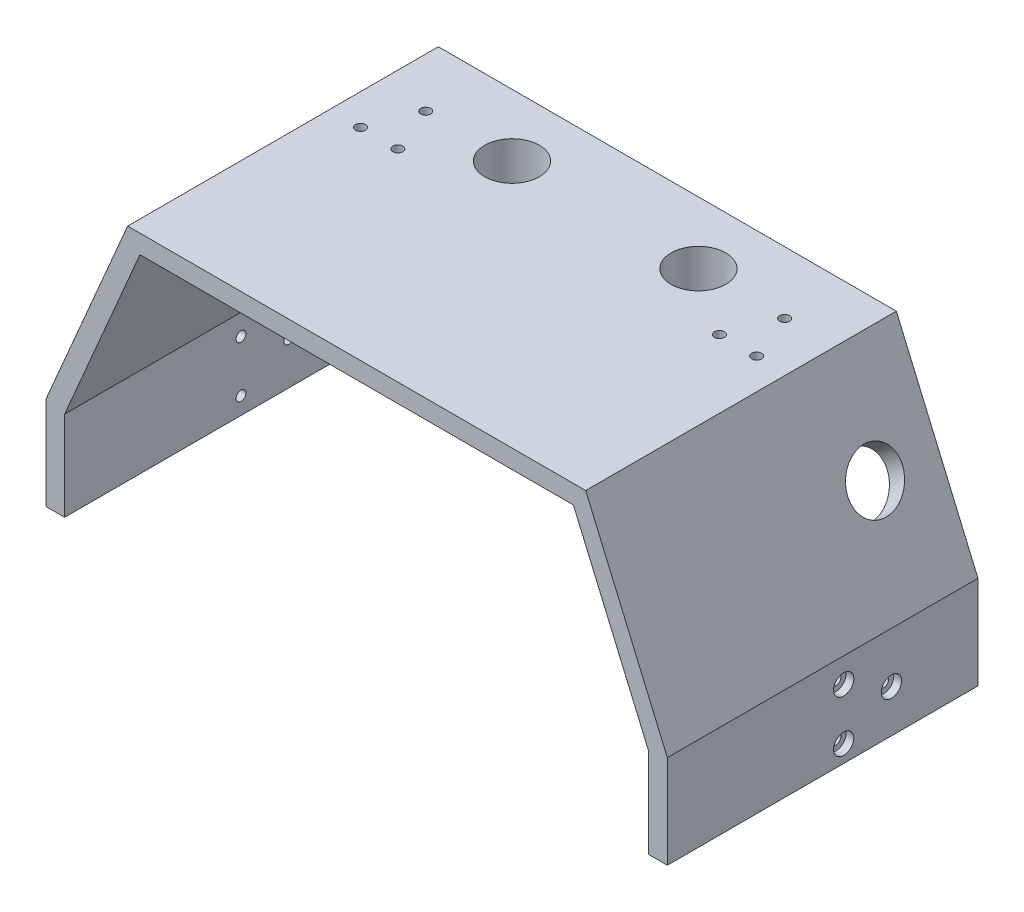
from build123d import *

# Parameters (mm, degrees)
SALIENTE_EXTRUIR1_DEPTH = 100
CORTAR_EXTRUIR1_REACH   = 170.346
CROQUIS3_R              = 8.8
CORTAR_EXTRUIR2_REACH   = 226.945
CROQUIS4_R              = 8.8
CORTAR_EXTRUIR3_DEPTH   = 0.5
CORTAR_EXTRUIR4_REACH   = 241.691
CROQUIS6_R              = 1.6
CROQUIS7_R              = 3.25
CORTAR_EXTRUIR5_DEPTH   = 2.5
CROQUIS11_R             = 10.3
CROQUIS11_R_2           = 8.8
SALIENTE_EXTRUIR2_DEPTH = 10
SALIENTE_EXTRUIR3_REACH = 201.802
CROQUIS12_R             = 10.3
CROQUIS12_R_2           = 8.8
CORTAR_EXTRUIR9_REACH   = 167.168
CROQUIS13_R             = 1.6


with BuildPart() as part:
    # Croquis1 → Saliente-Extruir1 (new body)
    with BuildSketch(Plane.XY):
        Polygon((-100, 25), (-100, -5), (-94, -5), (-94, 23.768453788), (-69.761533754, 80.324875029), (69.761533754, 80.324875029), (94, 23.768453788), (94, -5), (100, -5), (100, 25), (73.717910702, 86.324875029), (-73.717910702, 86.324875029), align=None)
    extrude(amount=SALIENTE_EXTRUIR1_DEPTH)

    # Croquis3 → Cortar-Extruir1 (cut, up to next)
    with BuildSketch(Plane(origin=(0, 86.324875029, 0), x_dir=(1, 0, 0), z_dir=(0, 1, 0)), mode=Mode.PRIVATE) as cortar_extruir1_sk1:
        with Locations(Location((-30, -20, 0), (0, 0, 270))):
            Circle(CROQUIS3_R)
    cortar_extruir1_tool1 = extrude(cortar_extruir1_sk1.sketch, amount=-CORTAR_EXTRUIR1_REACH, mode=Mode.PRIVATE) & part.part
    # Croquis3 → Cortar-Extruir1 (cut, up to next)
    with BuildSketch(Plane(origin=(0, 86.324875029, 0), x_dir=(1, 0, 0), z_dir=(0, 1, 0)), mode=Mode.PRIVATE) as cortar_extruir1_sk2:
        with Locations(Location((30, -20, 0), (0, 0, 270))):
            Circle(CROQUIS3_R)
    cortar_extruir1_tool2 = extrude(cortar_extruir1_sk2.sketch, amount=-CORTAR_EXTRUIR1_REACH, mode=Mode.PRIVATE) & part.part
    add(cortar_extruir1_tool1.solids().sort_by_distance((-30, 86.324875, 20))[0], mode=Mode.SUBTRACT)
    add(cortar_extruir1_tool2.solids().sort_by_distance((30, 86.324875, 20))[0], mode=Mode.SUBTRACT)

    # Cortar-Extruir2: up to this plane
    cortar_extruir2_end = Plane(origin=(-94, 23.768453788, 100), z_dir=(-0.9191450300180581, 0.3939192985791672, 0))
    # Croquis4 → Cortar-Extruir2 (cut, up to the surface)
    with BuildSketch(Plane(origin=(-87.479517168, 68.836107355, 0), x_dir=(0, 0, -1), z_dir=(-0.7858721058939679, 0.6183890629512945, 0)), mode=Mode.PRIVATE) as cortar_extruir2_sk1:
        with Locations(Location((-20, 9.96907102, 0), (0, 0, 270))):
            Circle(CROQUIS4_R)
    cortar_extruir2_tool1 = split(extrude(cortar_extruir2_sk1.sketch, amount=-CORTAR_EXTRUIR2_REACH, mode=Mode.PRIVATE), bisect_by=cortar_extruir2_end, keep=Keep.BOTH, mode=Mode.PRIVATE)
    cortar_extruir2 = cortar_extruir2_tool1.solids().sort_by_distance((-93.644282, 61.001693, 20))[0]
    add(cortar_extruir2, mode=Mode.SUBTRACT)

    # Simetría1: Cortar-Extruir2 across plane
    add(cortar_extruir2.mirror(Plane(origin=(0, 0, 0), x_dir=(0, 0, 1), z_dir=(1, 0, 0))), mode=Mode.SUBTRACT)

    # Croquis5 → Cortar-Extruir3 (cut)
    with BuildSketch(Plane.XZ.offset(-80.324875029)):
        with BuildLine():
            Line((14.875, 0), (15.175, 0))
            Line((15.175, 0), (15.175, 2.3))
            Line((15.175, 2.3), (3.784177586, 2.3))
            ThreePointArc((3.784177586, 2.3), (0, 3.1), (-3.784177586, 2.3))
            Line((-3.784177586, 2.3), (-15.175, 2.3))
            Line((-15.175, 2.3), (-15.175, 0))
            Line((-15.175, 0), (-14.875, 0))
            Line((-14.875, 0), (-14.875, 2))
            Line((-14.875, 2), (-3.720215048, 2))
            ThreePointArc((-3.720215048, 2), (0, 2.8), (3.720215048, 2))
            Line((3.720215048, 2), (14.875, 2))
            Line((14.875, 2), (14.875, 0))
        make_face()
        with BuildLine():
            Line((3.261901286, 0), (14.875, 0))
            Line((14.875, 0), (14.875, 2))
            Line((14.875, 2), (3.720215048, 2))
            ThreePointArc((3.720215048, 2), (0, 2.8), (-3.720215048, 2))
            Line((-3.720215048, 2), (-14.875, 2))
            Line((-14.875, 2), (-14.875, 0))
            Line((-14.875, 0), (-3.261901286, 0))
            ThreePointArc((-3.261901286, 0), (0, 0.8), (3.261901286, 0))
        make_face()
        with BuildLine():
            Line((-3.261901286, 0), (3.261901286, 0))
            ThreePointArc((3.261901286, 0), (0, 0.8), (-3.261901286, 0))
        make_face()
    extrude(amount=-CORTAR_EXTRUIR3_DEPTH, mode=Mode.SUBTRACT)

    # Croquis6 → Cortar-Extruir4 (cut, up to next)
    with BuildSketch(Plane.ZY.offset(100), mode=Mode.PRIVATE) as cortar_extruir4_sk1:
        with Locations(Location((43.227046774, 0.497681725, 0), (0, 0, 270))):
            Circle(CROQUIS6_R)
    cortar_extruir4_tool1 = extrude(cortar_extruir4_sk1.sketch, amount=-CORTAR_EXTRUIR4_REACH, mode=Mode.PRIVATE) & part.part
    # Croquis6 → Cortar-Extruir4 (cut, up to next)
    with BuildSketch(Plane.ZY.offset(100), mode=Mode.PRIVATE) as cortar_extruir4_sk2:
        with Locations(Location((27.863523387, 8.768453788, 0), (0, 0, 270))):
            Circle(CROQUIS6_R)
    cortar_extruir4_tool2 = extrude(cortar_extruir4_sk2.sketch, amount=-CORTAR_EXTRUIR4_REACH, mode=Mode.PRIVATE) & part.part
    # Croquis6 → Cortar-Extruir4 (cut, up to next)
    with BuildSketch(Plane.ZY.offset(100), mode=Mode.PRIVATE) as cortar_extruir4_sk3:
        with Locations(Location((43.227046774, 17.039225851, 0), (0, 0, 270))):
            Circle(CROQUIS6_R)
    cortar_extruir4_tool3 = extrude(cortar_extruir4_sk3.sketch, amount=-CORTAR_EXTRUIR4_REACH, mode=Mode.PRIVATE) & part.part
    cortar_extruir4_1 = cortar_extruir4_tool1.solids().sort_by_distance((-100, 0.497682, 43.227047))[0]
    add(cortar_extruir4_1, mode=Mode.SUBTRACT)
    cortar_extruir4_2 = cortar_extruir4_tool2.solids().sort_by_distance((-100, 8.768454, 27.863523))[0]
    add(cortar_extruir4_2, mode=Mode.SUBTRACT)
    cortar_extruir4_3 = cortar_extruir4_tool3.solids().sort_by_distance((-100, 17.039226, 43.227047))[0]
    add(cortar_extruir4_3, mode=Mode.SUBTRACT)
    cortar_extruir4 = cortar_extruir4_1 + cortar_extruir4_2 + cortar_extruir4_3  # Cortar-Extruir4 as one shape, for the pattern or mirror that repeats it

    # Croquis7 → Cortar-Extruir5 (cut)
    with BuildSketch(Plane.ZY.offset(100)):
        with Locations(Location((27.863523387, 8.768453788, 0), (0, 0, 270))):
            Circle(CROQUIS7_R)
        with Locations(Location((43.227046774, 0.497681725, 0), (0, 0, 270))):
            Circle(CROQUIS7_R)
        with Locations(Location((43.227046774, 17.039225851, 0), (0, 0, 270))):
            Circle(CROQUIS7_R)
    cortar_extruir5 = extrude(amount=-CORTAR_EXTRUIR5_DEPTH, mode=Mode.SUBTRACT)

    # Simetría2: Cortar-Extruir4, Cortar-Extruir5 across plane
    add(cortar_extruir4.mirror(Plane(origin=(0, 0, 0), x_dir=(0, 0, 1), z_dir=(1, 0, 0))), mode=Mode.SUBTRACT)
    add(cortar_extruir5.mirror(Plane(origin=(0, 0, 0), x_dir=(0, 0, 1), z_dir=(1, 0, 0))), mode=Mode.SUBTRACT)

    # Croquis11 → Saliente-Extruir2 (add)
    with BuildSketch(Plane.XZ.offset(-80.324875029)):
        with Locations(Location((-30, 20, 0), (0, 0, 90))):
            Circle(CROQUIS11_R)
        with Locations(Location((-30, 20, 0), (0, 0, 90))):
            Circle(CROQUIS11_R_2, mode=Mode.SUBTRACT)
        with Locations(Location((30, 20, 0), (0, 0, 90))):
            Circle(CROQUIS11_R)
        with Locations(Location((30, 20, 0), (0, 0, 90))):
            Circle(CROQUIS11_R_2, mode=Mode.SUBTRACT)
    extrude(amount=SALIENTE_EXTRUIR2_DEPTH)

    # Saliente-Extruir3: up to this plane
    saliente_extruir3_end = Plane(origin=(-94, 23.768453788, 100), z_dir=(-0.9191450300180581, 0.3939192985791672, 0))
    # Croquis12 → Saliente-Extruir3 (add, up to the surface)
    with BuildSketch(Plane(origin=(-63.903353991, 50.284435467, 0), x_dir=(0, 0, -1), z_dir=(-0.7858721058939679, 0.6183890629512945, 0)), mode=Mode.PRIVATE) as saliente_extruir3_sk1:
        with Locations(Location((-20, 9.96907102, 0), (0, 0, 90))):
            Circle(CROQUIS12_R)
        with Locations(Location((-20, 9.96907102, 0), (0, 0, 90))):
            Circle(CROQUIS12_R_2, mode=Mode.SUBTRACT)
    saliente_extruir3_tool1 = split(extrude(saliente_extruir3_sk1.sketch, amount=SALIENTE_EXTRUIR3_REACH, mode=Mode.PRIVATE), bisect_by=saliente_extruir3_end, keep=Keep.BOTH, mode=Mode.PRIVATE)
    add(saliente_extruir3_tool1.solids().sort_by_distance((-63.878865, 50.315557, 20))[0])

    # Croquis13 → Cortar-Extruir9 (cut, up to next)
    with BuildSketch(Plane.XZ.offset(-80.324875029), mode=Mode.PRIVATE) as cortar_extruir9_sk1:
        with Locations(Location((57.761533754, 20, 0), (0, 0, 270))):
            Circle(CROQUIS13_R)
    cortar_extruir9_tool1 = extrude(cortar_extruir9_sk1.sketch, amount=-CORTAR_EXTRUIR9_REACH, mode=Mode.PRIVATE) & part.part
    # Croquis13 → Cortar-Extruir9 (cut, up to next)
    with BuildSketch(Plane.XZ.offset(-80.324875029), mode=Mode.PRIVATE) as cortar_extruir9_sk2:
        with Locations(Location((51.761533754, 35, 0), (0, 0, 270))):
            Circle(CROQUIS13_R)
    cortar_extruir9_tool2 = extrude(cortar_extruir9_sk2.sketch, amount=-CORTAR_EXTRUIR9_REACH, mode=Mode.PRIVATE) & part.part
    # Croquis13 → Cortar-Extruir9 (cut, up to next)
    with BuildSketch(Plane.XZ.offset(-80.324875029), mode=Mode.PRIVATE) as cortar_extruir9_sk3:
        with Locations(Location((63.761533754, 35, 0), (0, 0, 270))):
            Circle(CROQUIS13_R)
    cortar_extruir9_tool3 = extrude(cortar_extruir9_sk3.sketch, amount=-CORTAR_EXTRUIR9_REACH, mode=Mode.PRIVATE) & part.part
    # Croquis13 → Cortar-Extruir9 (cut, up to next)
    with BuildSketch(Plane.XZ.offset(-80.324875029), mode=Mode.PRIVATE) as cortar_extruir9_sk4:
        with Locations(Location((-57.761533754, 20, 0), (0, 0, 270))):
            Circle(CROQUIS13_R)
    cortar_extruir9_tool4 = extrude(cortar_extruir9_sk4.sketch, amount=-CORTAR_EXTRUIR9_REACH, mode=Mode.PRIVATE) & part.part
    # Croquis13 → Cortar-Extruir9 (cut, up to next)
    with BuildSketch(Plane.XZ.offset(-80.324875029), mode=Mode.PRIVATE) as cortar_extruir9_sk5:
        with Locations(Location((-63.761533754, 35, 0), (0, 0, 270))):
            Circle(CROQUIS13_R)
    cortar_extruir9_tool5 = extrude(cortar_extruir9_sk5.sketch, amount=-CORTAR_EXTRUIR9_REACH, mode=Mode.PRIVATE) & part.part
    # Croquis13 → Cortar-Extruir9 (cut, up to next)
    with BuildSketch(Plane.XZ.offset(-80.324875029), mode=Mode.PRIVATE) as cortar_extruir9_sk6:
        with Locations(Location((-51.761533754, 35, 0), (0, 0, 270))):
            Circle(CROQUIS13_R)
    cortar_extruir9_tool6 = extrude(cortar_extruir9_sk6.sketch, amount=-CORTAR_EXTRUIR9_REACH, mode=Mode.PRIVATE) & part.part
    add(cortar_extruir9_tool1.solids().sort_by_distance((57.761534, 80.324875, 20))[0], mode=Mode.SUBTRACT)
    add(cortar_extruir9_tool2.solids().sort_by_distance((51.761534, 80.324875, 35))[0], mode=Mode.SUBTRACT)
    add(cortar_extruir9_tool3.solids().sort_by_distance((63.761534, 80.324875, 35))[0], mode=Mode.SUBTRACT)
    add(cortar_extruir9_tool4.solids().sort_by_distance((-57.761534, 80.324875, 20))[0], mode=Mode.SUBTRACT)
    add(cortar_extruir9_tool5.solids().sort_by_distance((-63.761534, 80.324875, 35))[0], mode=Mode.SUBTRACT)
    add(cortar_extruir9_tool6.solids().sort_by_distance((-51.761534, 80.324875, 35))[0], mode=Mode.SUBTRACT)


solid = part.part
